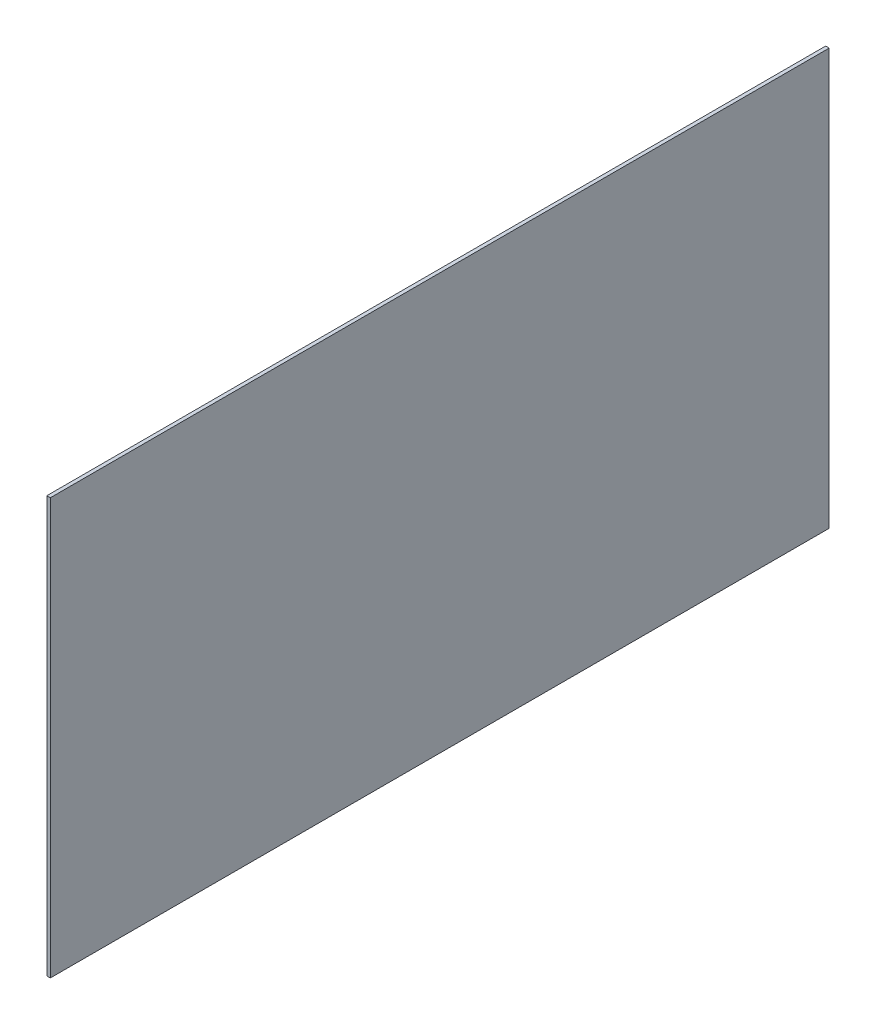
from build123d import *

# Parameters (mm, degrees)
SKETCH1_W           = 1.5
SKETCH1_H           = 176.3
EXTRUDE_THIN1_DEPTH = 165.1


with BuildPart() as part:
    # Sketch1 → Extrude-Thin1 (new body, symmetric)
    with BuildSketch(Plane.XY):
        with Locations((-418.175, 1080.25)):
            Rectangle(SKETCH1_W, SKETCH1_H)
    extrude(amount=EXTRUDE_THIN1_DEPTH, both=True)


solid = part.part
